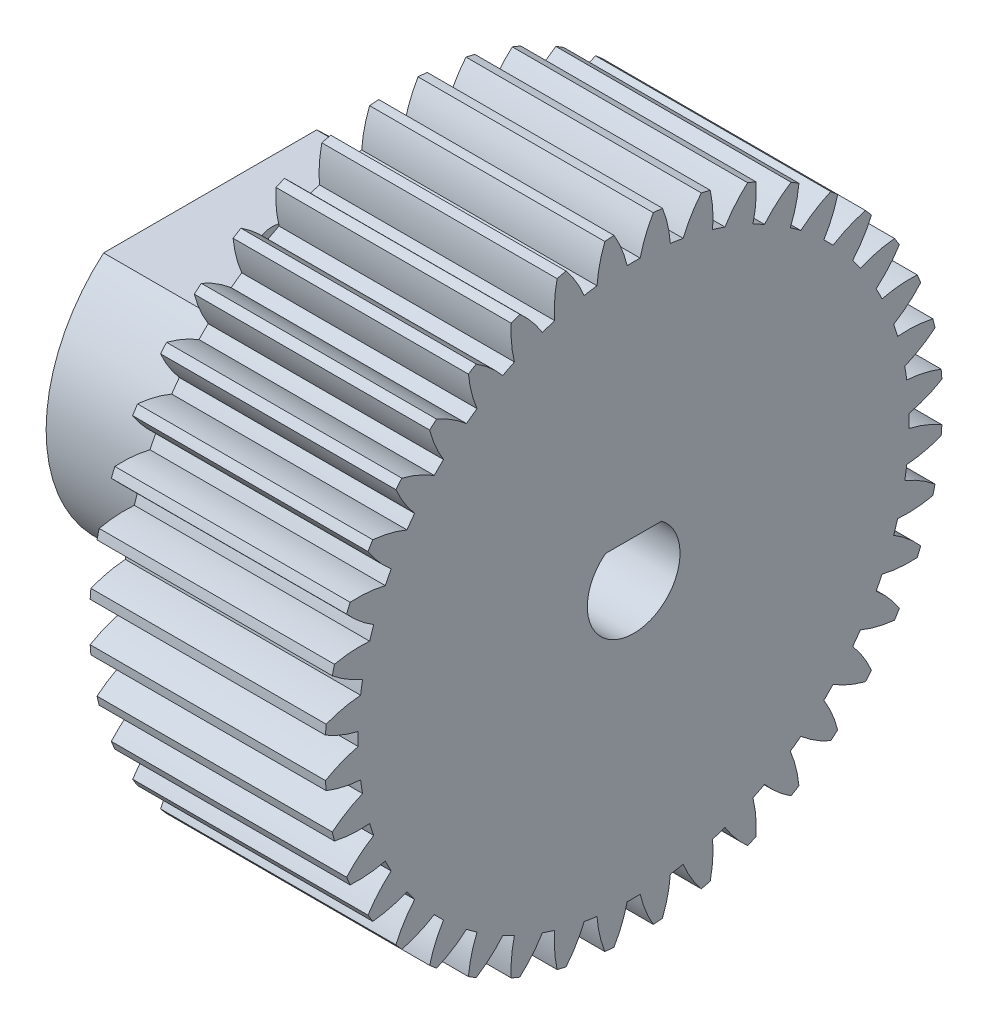
from build123d import *

# Parameters (mm, degrees)
BASPROSKE_W             = 12.7
BASPROSKE_H             = 16.66875
TOOTHCUT_DEPTH          = 27.776565372
TEETHCUTS_COUNT         = 40
TEETHCUTS_ANGLE         = 351
BORSKE_R                = 2.38125
BORE_DEPTH              = 50.8000508
SKETCH1_R               = 2.413
CUT_EXTRUDE1_DEPTH      = 12.7
SKETCH2_R               = 5.461
CUT_EXTRUDE2_DEPTH      = 12.7
CUT_EXTRUDE3_DEPTH      = 12.7
SKETCH4_R               = 5.461
SKETCH4_R_2             = 2.5019
BOSS_EXTRUDE1_DEPTH     = 12.7
BOSS_EXTRUDE2_DEPTH     = 12.7
SKETCH6_R               = 2.5019
BOSS_EXTRUDE3_DEPTH     = 10.16
CUT_EXTRUDE4_REACH      = 33.368
CUT_EXTRUDE4_END_RADIUS = 2.5019
SKETCH8_R               = 1.7526


with BuildPart() as part:
    # BasProSke → Base-Revolve (revolve)
    with BuildSketch(Plane(origin=(0, 0, 0), x_dir=(1, 0, 0), z_dir=(0, 1, 0)), mode=Mode.PRIVATE) as base_revolve_sk:
        with Locations((6.35, 8.334375)):
            Rectangle(BASPROSKE_W, BASPROSKE_H)
    revolve(base_revolve_sk.sketch.rotate(Axis((-10, 0, 0), (1, 0, 0)), 180), axis=Axis((-10, 0, 0), (1, 0, 0)))

    # TooCutSke → ToothCut (cut, through all)
    with BuildSketch(Plane(origin=(0, 0, 0), x_dir=(0, 0, -1), z_dir=(1, 0, 0))):
        with BuildLine():
            ThreePointArc((0.350893896, 14.867559799), (0, 14.8717), (-0.350893896, 14.867559799))
            ThreePointArc((-0.350893896, 14.867559799), (-0.644463151, 15.791243455), (-1.075185377, 16.659490407))
            ThreePointArc((-1.075185377, 16.659490407), (0, 16.69415), (1.075185377, 16.659490407))
            ThreePointArc((1.075185377, 16.659490407), (0.644463151, 15.791243455), (0.350893896, 14.867559799))
        make_face()
    toothcut = extrude(amount=TOOTHCUT_DEPTH, mode=Mode.SUBTRACT)

    # TeethCuts: ToothCut ×40 about axis
    teethcuts_axis = Axis((-10, 0, 0), (1, 0, 0))
    for i in range(1, TEETHCUTS_COUNT):
        add(toothcut.rotate(teethcuts_axis, i * TEETHCUTS_ANGLE / (TEETHCUTS_COUNT - 1)), mode=Mode.SUBTRACT)

    # BorSke → Bore (cut, symmetric)
    with BuildSketch(Plane(origin=(0, 0, 0), x_dir=(0, 0, -1), z_dir=(1, 0, 0))):
        with Locations(Location((0, 0, 0), (0, 0, 180))):
            Circle(BORSKE_R)
    extrude(amount=BORE_DEPTH, both=True, mode=Mode.SUBTRACT)

    # Sketch1 → Cut-Extrude1 (cut)
    with BuildSketch(Plane(origin=(12.7, 0, 0), x_dir=(0, 0, -1), z_dir=(1, 0, 0))):
        with Locations((-20.32, 20.32)):
            Circle(SKETCH1_R)
        with Locations((20.32, 20.32)):
            Circle(SKETCH1_R)
        with Locations((20.32, -20.32)):
            Circle(SKETCH1_R)
        with Locations((-20.32, -20.32)):
            Circle(SKETCH1_R)
    extrude(amount=-CUT_EXTRUDE1_DEPTH, mode=Mode.SUBTRACT)

    # Sketch2 → Cut-Extrude2 (cut)
    with BuildSketch(Plane(origin=(12.7, 0, 0), x_dir=(0, 0, -1), z_dir=(1, 0, 0))):
        Circle(SKETCH2_R)
    extrude(amount=-CUT_EXTRUDE2_DEPTH, mode=Mode.SUBTRACT)

    # Sketch3 → Cut-Extrude3 (cut)
    with BuildSketch(Plane(origin=(12.7, 0, 0), x_dir=(0, 0, -1), z_dir=(1, 0, 0))):
        with BuildLine():
            Line((19.793952373, -28.774208494), (6.771055825, -15.751311946))
            ThreePointArc((6.771055825, -15.751311946), (0, -17.145), (-6.771055825, -15.751311946))
            Line((-6.771055825, -15.751311946), (-19.793952373, -28.774208494))
            ThreePointArc((-19.793952373, -28.774208494), (0, -34.925), (19.793952373, -28.774208494))
        make_face()
        with BuildLine():
            Line((28.774208494, -19.793952373), (15.751311946, -6.771055825))
            ThreePointArc((15.751311946, -6.771055825), (17.145, 0), (15.751311946, 6.771055825))
            Line((15.751311946, 6.771055825), (28.774208494, 19.793952373))
            ThreePointArc((28.774208494, 19.793952373), (34.925, 0), (28.774208494, -19.793952373))
        make_face()
        with BuildLine():
            Line((-28.774208494, -19.793952373), (-15.751311946, -6.771055825))
            ThreePointArc((-15.751311946, -6.771055825), (-17.145, 0), (-15.751311946, 6.771055825))
            Line((-15.751311946, 6.771055825), (-28.774208494, 19.793952373))
            ThreePointArc((-28.774208494, 19.793952373), (-34.925, 0), (-28.774208494, -19.793952373))
        make_face()
        with BuildLine():
            Line((-6.771055825, 15.751311946), (-19.793952373, 28.774208494))
            ThreePointArc((-19.793952373, 28.774208494), (0, 34.925), (19.793952373, 28.774208494))
            Line((19.793952373, 28.774208494), (6.771055825, 15.751311946))
            ThreePointArc((6.771055825, 15.751311946), (0, 17.145), (-6.771055825, 15.751311946))
        make_face()
    extrude(amount=-CUT_EXTRUDE3_DEPTH, mode=Mode.SUBTRACT)

    # Sketch4 → Boss-Extrude1 (add)
    with BuildSketch(Plane(origin=(12.7, 0, 0), x_dir=(0, 0, -1), z_dir=(1, 0, 0))):
        Circle(SKETCH4_R)
        Circle(SKETCH4_R_2, mode=Mode.SUBTRACT)
    extrude(amount=-BOSS_EXTRUDE1_DEPTH)

    # Sketch5 → Boss-Extrude2 (add)
    with BuildSketch(Plane(origin=(12.7, 0, 0), x_dir=(0, 0, -1), z_dir=(1, 0, 0))):
        with BuildLine():
            Line((-1.511246638, 1.9939), (1.511246638, 1.9939))
            ThreePointArc((1.511246638, 1.9939), (0, 2.5019), (-1.511246638, 1.9939))
        make_face()
    extrude(amount=-BOSS_EXTRUDE2_DEPTH)

    # Sketch6 → Boss-Extrude3 (add)
    with BuildSketch(Plane.ZY):
        with BuildLine():
            Line((-5.748893164, 6.731), (5.748893164, 6.731))
            ThreePointArc((5.748893164, 6.731), (0, -8.8519), (-5.748893164, 6.731))
        make_face()
        with Locations(Location((0, 0, 0), (0, 0, 127.159762767))):
            Circle(SKETCH6_R, mode=Mode.SUBTRACT)
    extrude(amount=BOSS_EXTRUDE3_DEPTH)

    # Cut-Extrude4: up to this cylinder (the profile starts outside it)
    cut_extrude4_end = Plane(origin=(-5.08, 0, 0), z_dir=(1, 0, 0)) * Cylinder(CUT_EXTRUDE4_END_RADIUS, 72.7398, mode=Mode.PRIVATE)
    # Sketch8 → Cut-Extrude4 (cut, up to the surface)
    with BuildSketch(Plane(origin=(0, 6.731, 0), x_dir=(1, 0, 0), z_dir=(0, 1, 0)), mode=Mode.PRIVATE) as cut_extrude4_sk1:
        with Locations(Location((-5.08, 0, 0), (0, 0, 270))):
            Circle(SKETCH8_R)
    cut_extrude4_tool1 = extrude(cut_extrude4_sk1.sketch, amount=-CUT_EXTRUDE4_REACH, mode=Mode.PRIVATE) - cut_extrude4_end
    add(cut_extrude4_tool1.solids().sort_by_distance((-5.08, 6.731, 0))[0], mode=Mode.SUBTRACT)


solid = part.part
